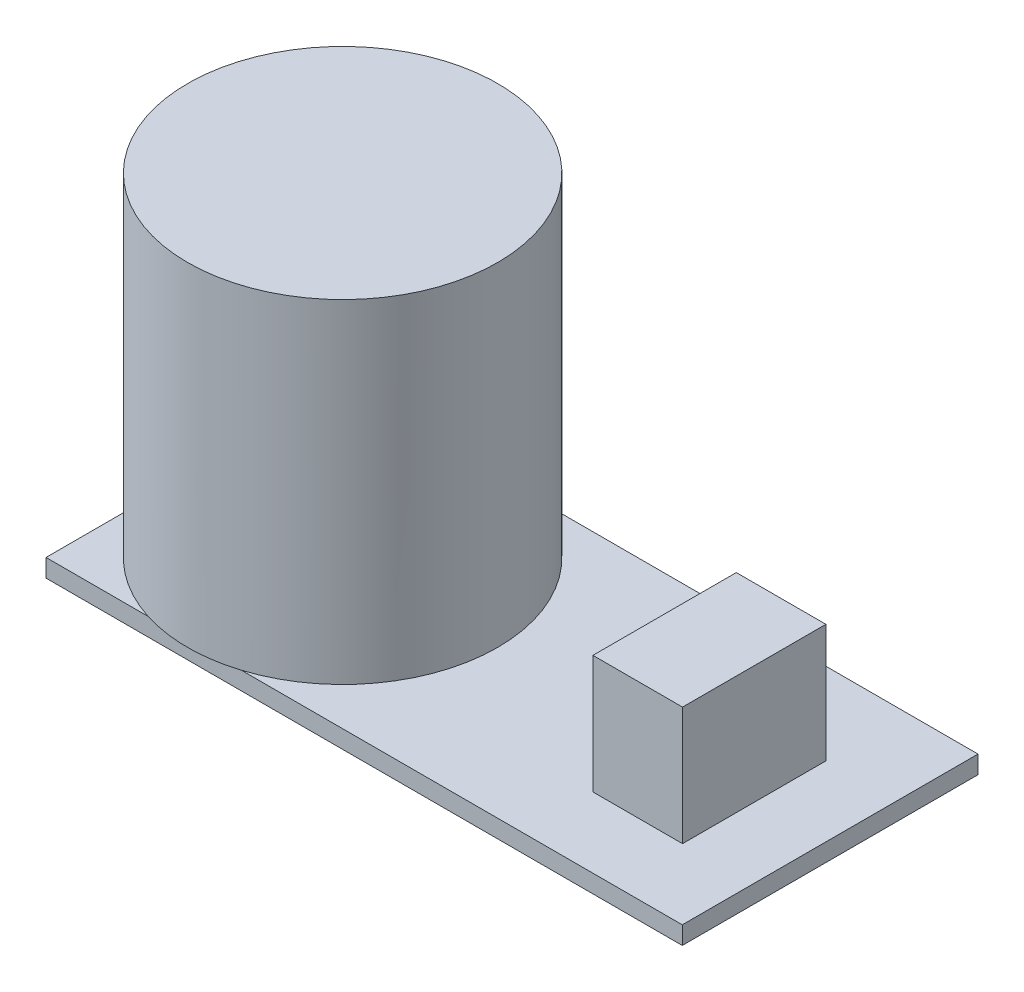
from build123d import *

# Parameters (mm, degrees)
SKETCH1_W           = 35.5
SKETCH1_H           = 16.5
BOSS_EXTRUDE1_DEPTH = 1
SKETCH2_R           = 8.65
BOSS_EXTRUDE2_DEPTH = 18.6
SKETCH3_W           = 5
SKETCH3_H           = 8
BOSS_EXTRUDE3_DEPTH = 6.6


with BuildPart() as part:
    # Sketch1 → Boss-Extrude1 (new body)
    with BuildSketch(Plane(origin=(0, 0, 0), x_dir=(1, 0, 0), z_dir=(0, 1, 0))):
        Rectangle(SKETCH1_W, SKETCH1_H)
    extrude(amount=BOSS_EXTRUDE1_DEPTH)

    # Sketch2 → Boss-Extrude2 (add)
    with BuildSketch(Plane(origin=(0, 1, 0), x_dir=(1, 0, 0), z_dir=(0, 1, 0))):
        with Locations((-9.45, 0)):
            Circle(SKETCH2_R)
    extrude(amount=BOSS_EXTRUDE2_DEPTH)

    # Sketch3 → Boss-Extrude3 (add)
    with BuildSketch(Plane(origin=(0, 1, 0), x_dir=(1, 0, 0), z_dir=(0, 1, 0))):
        with Locations((11.337780318, -0.323708933)):
            Rectangle(SKETCH3_W, SKETCH3_H)
    extrude(amount=BOSS_EXTRUDE3_DEPTH)


solid = part.part
